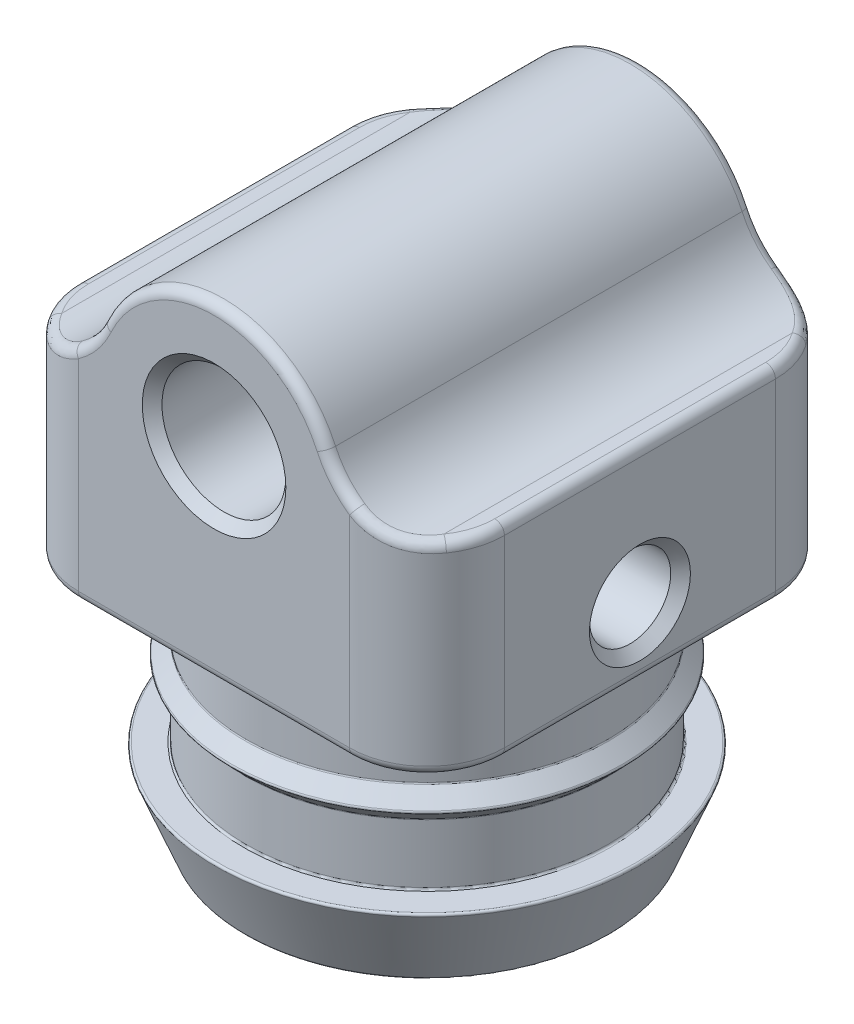
from build123d import *

# Parameters (mm, degrees)
SKETCH1_R                  = 3.2
BOSS_EXTRUDE1_DEPTH        = 11
SKETCH3_R                  = 4
CUT_EXTRUDE1_DEPTH         = 18
M5X0_8_TAPPED_HOLE1_REACH  = 35.471
M5X0_8_TAPPED_HOLE1_BORE_R = 2.1
FILLET3_R                  = 0.09921875
CHAMFER1_SIZE              = 0.508
FILLET7_R                  = 4.5
FILLET6_R                  = 4
FILLET8_R                  = 0.5


with BuildPart() as part:
    # Sketch1 → Boss-Extrude1 (new, symmetric)
    with BuildSketch(Plane.XY):
        with BuildLine():
            Line((-11, 0), (-6.35, 0))
            ThreePointArc((-6.35, 0), (0, 6.35), (6.35, 0))
            Line((6.35, 0), (11, 0))
            Line((11, 0), (11, -10.5))
            Line((11, -10.5), (-11, -10.5))
            Line((-11, -10.5), (-11, 0))
        make_face()
        Circle(SKETCH1_R, mode=Mode.SUBTRACT)
    extrude(amount=BOSS_EXTRUDE1_DEPTH, both=True)

    # Sketch2 → Revolve1 (revolve)
    with BuildSketch(Plane.XY, mode=Mode.PRIVATE) as revolve1_sk:
        Polygon((0, -10), (9.365, -10), (9.365, -13.96875), (10.15875, -14.7625), (9.365, -15.55625), (9.365, -18.73125), (10.9525, -18.73125), (9.365, -22.7), (0, -22.7), align=None)
    revolve(revolve1_sk.sketch.rotate(Axis((0, 9.54404991, 0), (0, -1, 0)), 180), axis=Axis((0, 9.54404991, 0), (0, -1, 0)))

    # Sketch3 → Cut-Extrude1 (cut)
    with BuildSketch(Plane.XZ.offset(22.7)):
        Circle(SKETCH3_R)
    extrude(amount=-CUT_EXTRUDE1_DEPTH, mode=Mode.SUBTRACT)

    # M5x0.8 Tapped Hole1 bore → M5x0.8 Tapped Hole1 (cut, up to next)
    with BuildSketch(Plane(origin=(11, 0, 0), x_dir=(0, 0, -1), z_dir=(1, 0, 0)), mode=Mode.PRIVATE) as m5x0_8_tapped_hole1_sk1:
        with Locations((0, -7)):
            Circle(M5X0_8_TAPPED_HOLE1_BORE_R)
    m5x0_8_tapped_hole1_tool1 = extrude(m5x0_8_tapped_hole1_sk1.sketch, amount=-M5X0_8_TAPPED_HOLE1_REACH, mode=Mode.PRIVATE) & part.part
    add(m5x0_8_tapped_hole1_tool1.solids().sort_by_distance((11, -7, 0))[0], mode=Mode.SUBTRACT)

    # Fillet3
    fillet3_edges = [part.edges().sort_by_distance(p)[0] for p in [
        (9.365, -10.5, 0),
        (9.365, -13.96875, 0),
        (10.15875, -14.7625, 0),
        (9.365, -15.55625, 0),
        (9.365, -18.73125, 0),
        (10.9525, -18.73125, 0),
        (9.365, -22.7, 0),
        (-4, -4.7, 0),
        (-4, -22.7, 0),
        (3.71356177, -8.483422073, -1.486424901),
    ]]
    fillet(fillet3_edges, radius=FILLET3_R)

    # Chamfer1
    chamfer1_edges = [part.edges().sort_by_distance(p)[0] for p in [
        (-3.2, 0, -11),
        (-3.2, 0, 11),
        (11, -7, 2.1),
    ]]
    chamfer(chamfer1_edges, length=CHAMFER1_SIZE)

    # Fillet7
    fillet7_edges = [part.edges().sort_by_distance(p)[0] for p in [
        (6.35, 0, 0),
        (-6.35, 0, 0),
    ]]
    fillet(fillet7_edges, radius=FILLET7_R)

    # Fillet6
    fillet6_edges = [part.edges().sort_by_distance(p)[0] for p in [
        (11, -5.25, -11),
        (-11, -5.25, -11),
        (-11, -5.25, 11),
        (11, -5.25, 11),
    ]]
    fillet(fillet6_edges, radius=FILLET6_R)

    # Fillet8
    fillet8_edges = [part.edges().sort_by_distance(p)[0] for p in [
        (10.707510274, 0, 8.501455151),
        (10.707510274, 0, -8.501455151),
        (6.298677383, 1.765858158, 11),
        (8.469550334, 0.224389567, 10.720271757),
        (8.469550334, 0.224389567, -10.720271757),
        (0, -10.5, -11),
        (-6.298677383, 1.765858158, -11),
        (0, -10.5, 11),
        (-11, -10.5, 0),
        (9.828427125, -10.5, 9.828427125),
        (-9.828427125, -10.5, 9.828427125),
        (-9.828427125, -10.5, -9.828427125),
        (9.828427125, -10.5, -9.828427125),
        (-11, 0, 0),
        (-8.469550334, 0.224389567, 10.720271757),
        (-8.469550334, 0.224389567, -10.720271757),
        (-10.707510274, 0, 8.501455151),
        (-10.707510274, 0, -8.501455151),
        (0, 6.35, -11),
        (0, 6.35, 11),
        (-6.298677383, 1.765858158, 11),
        (6.298677383, 1.765858158, -11),
        (11, 0, 0),
        (11, -10.5, 0),
    ]]
    fillet(fillet8_edges, radius=FILLET8_R)


solid = part.part
